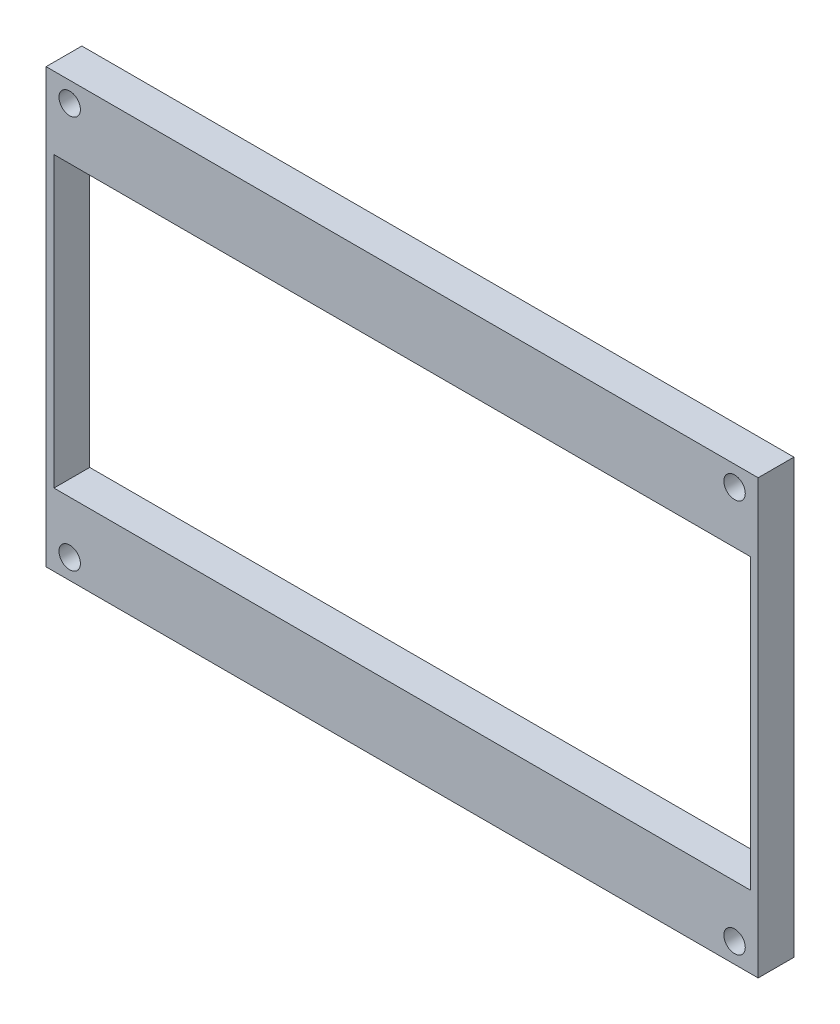
from build123d import *

# Parameters (mm, degrees)
ESBO_O1_W                = 99.6
ESBO_O1_H                = 60.6
ESBO_O1_R                = 1.5
ESBO_O1_W_2              = 97.4
ESBO_O1_H_2              = 40.4
RESSALTO_EXTRUS_O1_DEPTH = 5


with BuildPart() as part:
    # Esboço1 → Ressalto-extrusão1 (new body)
    with BuildSketch(Plane.XY):
        with Locations((23, 24.5)):
            Rectangle(ESBO_O1_W, ESBO_O1_H)
        with Locations((-23.5, -3)):
            Circle(ESBO_O1_R, mode=Mode.SUBTRACT)
        with Locations((69.5, -3)):
            Circle(ESBO_O1_R, mode=Mode.SUBTRACT)
        with Locations((69.5, 52)):
            Circle(ESBO_O1_R, mode=Mode.SUBTRACT)
        with Locations((-23.5, 52)):
            Circle(ESBO_O1_R, mode=Mode.SUBTRACT)
        with Locations((23, 24.5)):
            Rectangle(ESBO_O1_W_2, ESBO_O1_H_2, mode=Mode.SUBTRACT)
    extrude(amount=RESSALTO_EXTRUS_O1_DEPTH)


solid = part.part
